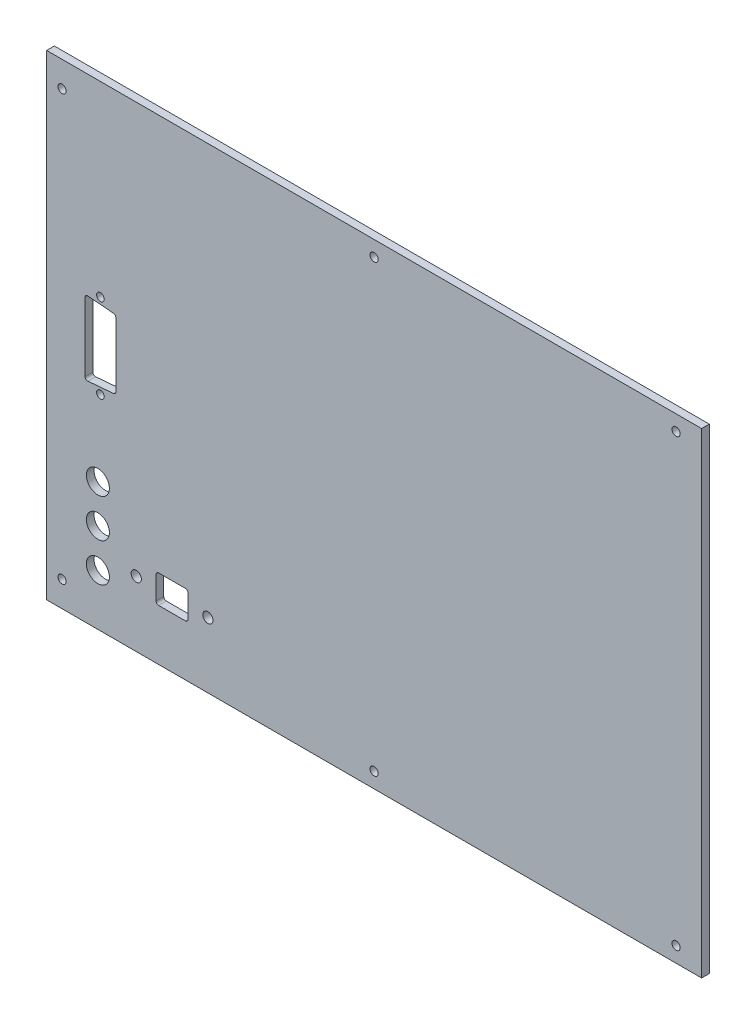
from build123d import *

# Parameters (mm, degrees)
SKETCH2_W           = 256
SKETCH2_H           = 186
BOSS_EXTRUDE1_DEPTH = 3
SKETCH3_R           = 1.6
CUT_EXTRUDE1_DEPTH  = 4
SKETCH4_R           = 2
SKETCH4_W           = 12.5
SKETCH4_H           = 11
CUT_EXTRUDE2_DEPTH  = 10
FILLET1_R           = 1
SKETCH5_R           = 4.5
CUT_EXTRUDE3_DEPTH  = 10
SKETCH7_R           = 1.5
CUT_EXTRUDE4_DEPTH  = 4
FILLET2_R           = 1


with BuildPart() as part:
    # Sketch2 → Boss-Extrude1 (new body)
    with BuildSketch(Plane.XY):
        with Locations((128, 93)):
            Rectangle(SKETCH2_W, SKETCH2_H)
    extrude(amount=BOSS_EXTRUDE1_DEPTH)

    # Sketch3 → Cut-Extrude1 (cut, through all)
    with BuildSketch(Plane.XY.offset(3)):
        with Locations((6, 176)):
            Circle(SKETCH3_R)
        with Locations((128, 180)):
            Circle(SKETCH3_R)
        with Locations((246, 180)):
            Circle(SKETCH3_R)
        with Locations((246, 6)):
            Circle(SKETCH3_R)
        with Locations((128, 6)):
            Circle(SKETCH3_R)
        with Locations((6, 10)):
            Circle(SKETCH3_R)
    extrude(amount=-CUT_EXTRUDE1_DEPTH, mode=Mode.SUBTRACT)

    # Sketch4 → Cut-Extrude2 (cut)
    with BuildSketch(Plane.XY.offset(3)):
        with Locations((35, 25.5)):
            Circle(SKETCH4_R)
        with Locations((63, 25.5)):
            Circle(SKETCH4_R)
        with Locations((49, 25.5)):
            Rectangle(SKETCH4_W, SKETCH4_H)
    extrude(amount=-CUT_EXTRUDE2_DEPTH, mode=Mode.SUBTRACT)

    # Fillet1
    fillet1_edges = [part.edges().sort_by_distance(p)[0] for p in [
        (42.75, 20, 1.5),
        (42.75, 31, 1.5),
        (55.25, 31, 1.5),
        (55.25, 20, 1.5),
    ]]
    fillet(fillet1_edges, radius=FILLET1_R)

    # Sketch5 → Cut-Extrude3 (cut)
    with BuildSketch(Plane.XY.offset(3)):
        with Locations((20, 35)):
            Circle(SKETCH5_R)
        with Locations((20, 20)):
            Circle(SKETCH5_R)
        with Locations((20, 50)):
            Circle(SKETCH5_R)
    extrude(amount=-CUT_EXTRUDE3_DEPTH, mode=Mode.SUBTRACT)

    # Sketch7 → Cut-Extrude4 (cut, through all)
    with BuildSketch(Plane(origin=(161.992525703, 0.203186411, 3), x_dir=(1, 0, 0), z_dir=(0, 0, 1))):
        with Locations((-140.992525703, 112.796813589)):
            Circle(SKETCH7_R)
        with Locations((-140.992525703, 79.796813589)):
            Circle(SKETCH7_R)
        Polygon((-146.992525703, 110.796813589), (-146.992525703, 81.796813589), (-134.992525703, 82.796813589), (-134.992525703, 109.796813589), align=None)
    extrude(amount=-CUT_EXTRUDE4_DEPTH, mode=Mode.SUBTRACT)

    # Fillet2
    fillet2_edges = [part.edges().sort_by_distance(p)[0] for p in [
        (15, 111, 1.5),
        (27, 110, 1.5),
        (27, 83, 1.5),
        (15, 82, 1.5),
    ]]
    fillet(fillet2_edges, radius=FILLET2_R)


solid = part.part
